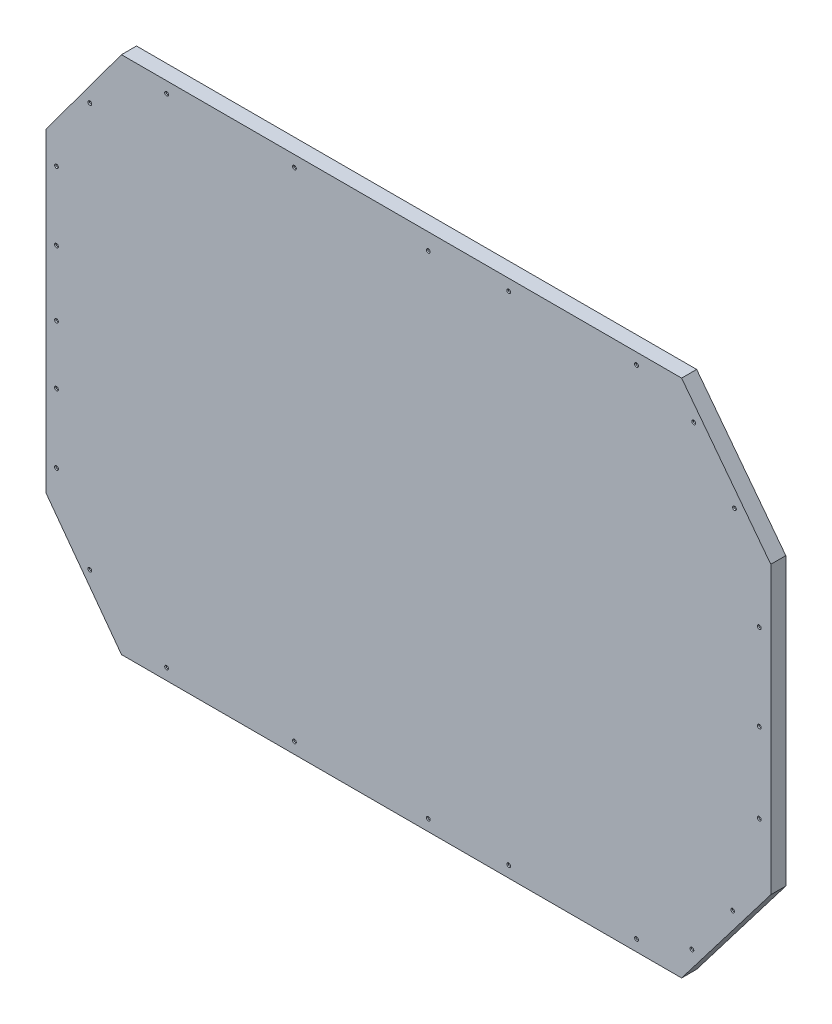
from build123d import *

# Parameters (mm, degrees)
BOSS_EXTRUDE1_DEPTH                               = 20
CSK_FOR_3_FLAT_HEAD_MACHINE_SCREW_100_D           = 2.794
CSK_FOR_3_FLAT_HEAD_MACHINE_SCREW_100_DEPTH       = 20
CSK_FOR_3_FLAT_HEAD_MACHINE_SCREW_100_CSINK_D     = 5.0546
CSK_FOR_3_FLAT_HEAD_MACHINE_SCREW_100_CSINK_ANGLE = 100


with BuildPart() as part:
    # Sketch2 → Boss-Extrude1 (new body)
    with BuildSketch(Plane.XY):
        Polygon((-118.58, 345.487717935), (-863.58, 345.487717935), (-963.71, 209.828898833), (-963.71, -209.828898833), (-863.58, -345.487717935), (-118.58, -345.487717935), (0, -190.295), (0, 190.295), align=None)
    extrude(amount=BOSS_EXTRUDE1_DEPTH)

    # CSK for #3 Flat Head Machine Screw (100)1
    with Locations(Plane.XY.offset(20)):
        with Locations((-950.019491684, 82.340523551), (-950.019491684, 173.75453442), (-905.654330921, 268.705699397), (-803.58, 330.487717935), (-633.58, 330.487717935), (-455.480152545, 323.52139094), (-348.58, 330.487717935), (-178.58, 330.487717935), (-102.481993543, 302.529132765), (-48.296375955, 230.66872053), (-15.328698966, 110.295), (-15.328698966, -4.236762626), (-15.328698966, -110.295), (-50.699956706, -233.856324756), (-104.885574294, -305.716736991), (-178.58, -330.487717935), (-348.58, -330.487717935), (-455.480152545, -330.487717935), (-633.58, -330.487717935), (-803.58, -330.487717935), (-905.654330921, -268.716630557), (-950.019491684, -173.76546558), (-950.019491684, -82.351454711), (-950.019491684, -4.236762626)):
            CounterSinkHole(CSK_FOR_3_FLAT_HEAD_MACHINE_SCREW_100_D / 2, CSK_FOR_3_FLAT_HEAD_MACHINE_SCREW_100_CSINK_D / 2, depth=CSK_FOR_3_FLAT_HEAD_MACHINE_SCREW_100_DEPTH, counter_sink_angle=CSK_FOR_3_FLAT_HEAD_MACHINE_SCREW_100_CSINK_ANGLE)


solid = part.part
